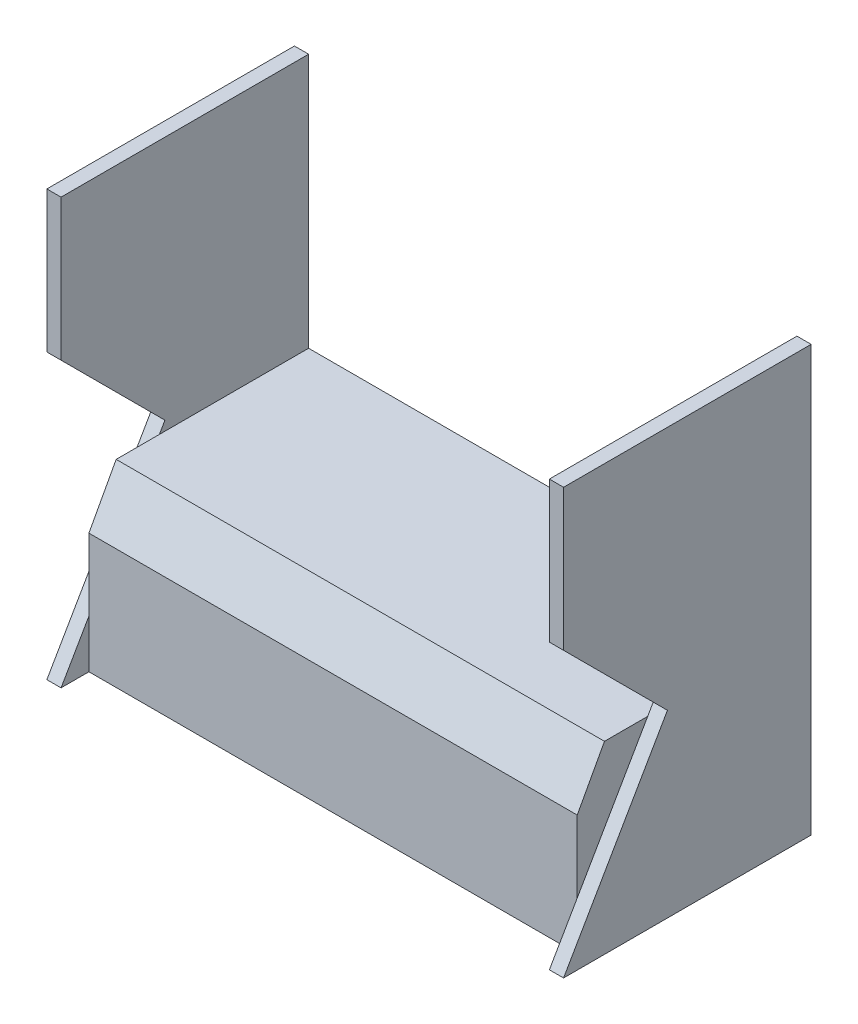
from build123d import *

# Parameters (mm, degrees)
EXTRUDE_1_DEPTH     = 50
EXTRUDE_2_DEPTH     = 1720
EXTRUDE_START       = 1770
EXTRUDE_3_DEPTH     = 50
SKETCH_3_W          = 1820
SKETCH_3_H          = 1497
CUT_EXTRUDE_1_DEPTH = 850


with BuildPart() as part:
    # 草图1 → 凸台-拉伸1 (new body)
    with BuildSketch(Plane(origin=(0, 0, 0), x_dir=(0, 0, -1), z_dir=(1, 0, 0))):
        Polygon((0, 0), (365.848742481, 633.668609863), (0, 999.517352344), (0, 1497), (1722, 1497), (1722, 0), align=None)
    extrude(amount=EXTRUDE_1_DEPTH)

    # 草图2 → 凸台-拉伸2 (add)
    with BuildSketch(Plane(origin=(50, 0, 0), x_dir=(0, 0, -1), z_dir=(1, 0, 0))):
        Polygon((1722, 600), (194.068411452, 600), (98.124217521, 423), (98.124217521, 0), (1722, 0), align=None)
    extrude(amount=EXTRUDE_2_DEPTH)

    # 草图1<2> → 凸台-拉伸3 (add)
    with BuildSketch(Plane(origin=(0, 0, 0), x_dir=(0, 0, -1), z_dir=(1, 0, 0)).offset(EXTRUDE_START)):
        Polygon((0, 0), (365.848742481, 633.668609863), (0, 999.517352344), (0, 1497), (1722, 1497), (1722, 0), align=None)
    extrude(amount=EXTRUDE_3_DEPTH)

    # 草图3 → 切除-拉伸1 (cut)
    with BuildSketch(Plane(origin=(0, 0, -1722), x_dir=(-1, 0, 0), z_dir=(0, 0, -1))):
        with Locations((-910, 748.5)):
            Rectangle(SKETCH_3_W, SKETCH_3_H)
    extrude(amount=-CUT_EXTRUDE_1_DEPTH, mode=Mode.SUBTRACT)


solid = part.part
